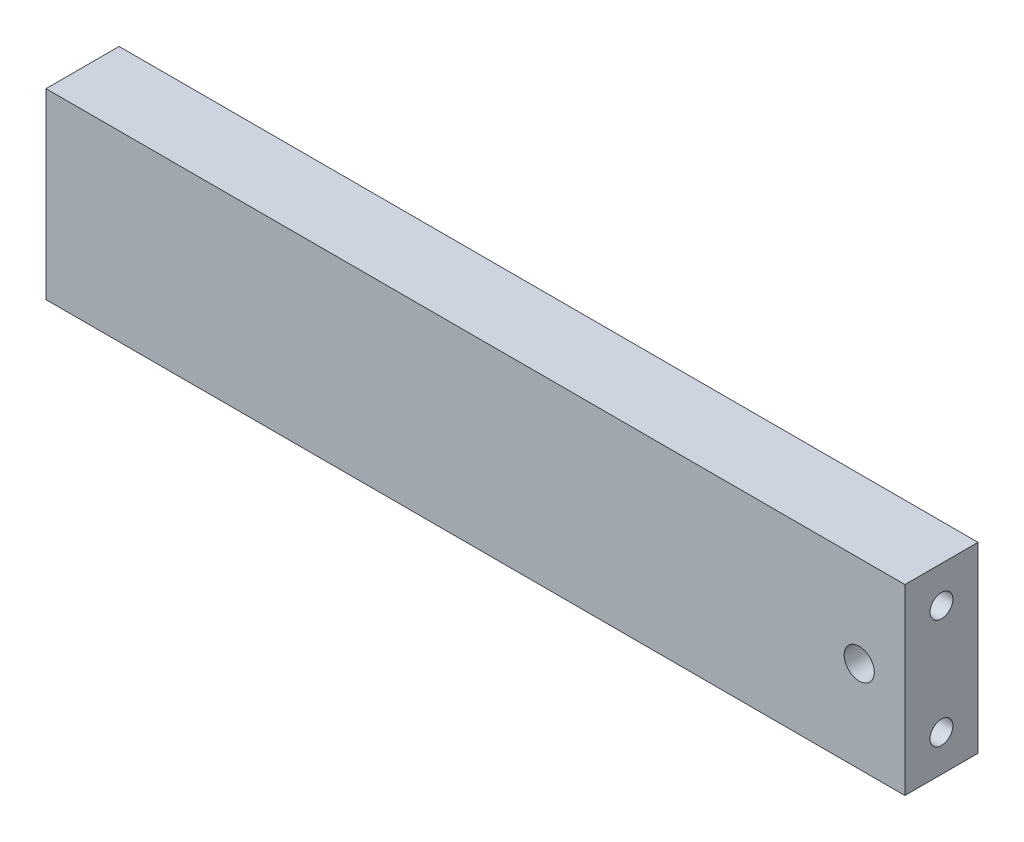
from build123d import *

# Parameters (mm, degrees)
SKETCH_1_W                      = 94
SKETCH_1_H                      = 20
EXTRUDE_1_DEPTH                 = 8
M4_ALTADJUST_D                  = 3.3
M4_ALTADJUST_DEPTH              = 8
M3_HORIZONTALBAR_FIX_AT_2_COUNT = 2
M3_HORIZONTALBAR_FIX_AT_2_PITCH = 12


with BuildPart() as part:
    # 스케치1 → 보스-돌출1 (new body)
    with BuildSketch(Plane.XY):
        Rectangle(SKETCH_1_W, SKETCH_1_H)
    extrude(amount=EXTRUDE_1_DEPTH)

    # M4-ALTADJUST
    with Locations(Plane.XY.offset(8)):
        with Locations((42, 0)):
            Hole(M4_ALTADJUST_D / 2, depth=M4_ALTADJUST_DEPTH)

    # 스케치5 → M3-HORIZONTALBAR_FIX (revolve, cut)
    with BuildSketch(Plane(origin=(47, 6, 4), x_dir=(0, 0, -1), z_dir=(0, 1, 0))):
        Polygon((0, 0), (0, 9.251075774), (1.25, 8.5), (1.25, 0), align=None)
    m3_horizontalbar_fix = revolve(axis=Axis((53.35, 6, 4), (-1, 0, 0)), mode=Mode.SUBTRACT)

    # M3-HORIZONTALBAR_FIX at 2: M3-HORIZONTALBAR_FIX ×2
    with Locations(*[(0, -i * M3_HORIZONTALBAR_FIX_AT_2_PITCH, 0) for i in range(1, M3_HORIZONTALBAR_FIX_AT_2_COUNT)]):
        add(m3_horizontalbar_fix, mode=Mode.SUBTRACT)

    # 대칭 복사1: M3-HORIZONTALBAR_FIX across plane
    add(m3_horizontalbar_fix.mirror(Plane(origin=(0, 0, 0), x_dir=(0, 0, 1), z_dir=(1, 0, 0))), mode=Mode.SUBTRACT)

    # 대칭 복사1 copy 1 sketch → 대칭 복사1 copy 1 (revolve, cut)
    with BuildSketch(Plane(origin=(-47, -6, 4), x_dir=(0, 0, -1), z_dir=(0, 1, 0))):
        Polygon((0, 0), (0, -9.251075774), (1.25, -8.5), (1.25, 0), align=None)
    revolve(axis=Axis((-53.35, -6, 4), (-1, 0, 0)), mode=Mode.SUBTRACT)


solid = part.part
